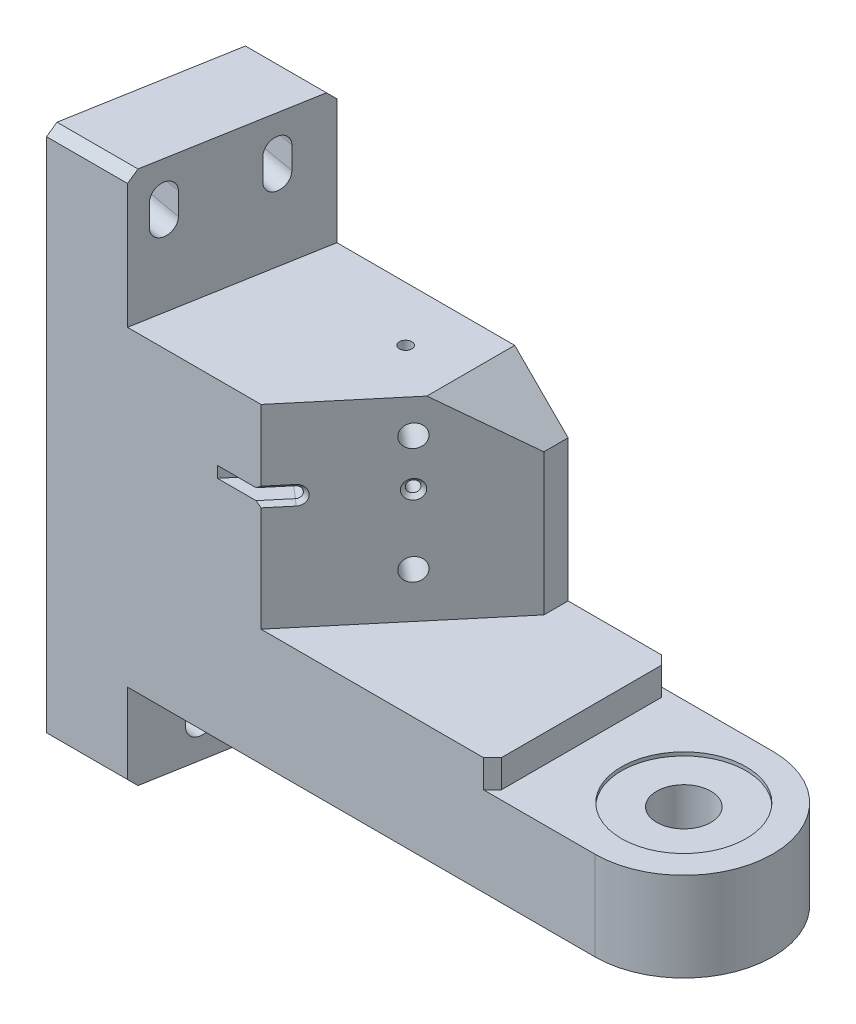
from build123d import *

# Parameters (mm, degrees)
SKETCH1_W                              = 181.864
SKETCH1_H                              = 50.8
EXTRUDE1_DEPTH                         = 152.4
EXTRUDE2_DEPTH                         = 153.4
EXTRUDE3_DEPTH                         = 38.1
EXTRUDE4_DEPTH                         = 55.5498
SKETCH5_W                              = 54.61
SKETCH5_H                              = 50.8
EXTRUDE5_DEPTH                         = 7.9502
EXTRUDE6_DEPTH                         = 25.4
EXTRUDE7_DEPTH                         = 32.584173829
LPATTERN1_COUNT                        = 2
LPATTERN1_PITCH                        = 127
LPATTERN1_COUNT_DIR2                   = 2
LPATTERN1_PITCH_DIR2                   = 27.94
F_1_4_20_TAPPED_HOLE1_D                = 5.1054
F_1_4_20_TAPPED_HOLE1_DEPTH            = 16.51
F_1_4_20_TAPPED_HOLE1_CBORE_D          = 6.35
F_1_4_20_TAPPED_HOLE1_CBORE_DEPTH      = 12.7
F_1_4_20_TAPPED_HOLE1_TIP              = 1.533816902
EXTRUDE9_DEPTH                         = 128
CHAMFER1_SIZE                          = 2.54
CHAMFER2_SIZE                          = 15.24
EXTRUDE10_DEPTH                        = 32.584173829
SCREW_THRU_HOLE_AND_CBORE_D            = 15.4686
SCREW_THRU_HOLE_AND_CBORE_CBORE_D      = 35.56
SCREW_THRU_HOLE_AND_CBORE_CBORE_DEPTH  = 1.016
F_1_8_0_125_DIAMETER_HOLE1_D           = 3.19024
F_1_8_0_125_DIAMETER_HOLE1_DEPTH       = 9.525
F_1_8_0_125_DIAMETER_HOLE1_CSINK_D     = 5.334
F_1_8_0_125_DIAMETER_HOLE1_CSINK_ANGLE = 90
F_1_8_0_125_DIAMETER_HOLE1_TIP         = 0.958444791
CUT_EXTRUDE1_DEPTH                     = 9.525
CHAMFER3_SIZE                          = 1.0795
F_9_64_0_14063_DIAMETER_HOLE1_D        = 3.572002
F_9_64_0_14063_DIAMETER_HOLE1_DEPTH    = 43.18
F_1_16_0_0625_DIAMETER_HOLE1_D         = 1.5875
F_1_16_0_0625_DIAMETER_HOLE1_DEPTH     = 16.51


with BuildPart() as part:
    # Sketch1 → Extrude1 (new body)
    with BuildSketch(Plane(origin=(0, 0, 0), x_dir=(1, 0, 0), z_dir=(0, 1, 0))):
        with Locations((-65.532, 0)):
            Rectangle(SKETCH1_W, SKETCH1_H)
    extrude(amount=EXTRUDE1_DEPTH)

    # Sketch2 → Extrude2 (cut, through all)
    with BuildSketch(Plane(origin=(0, 152.4, 0), x_dir=(1, 0, 0), z_dir=(0, 1, 0))):
        Polygon((-156.464, -25.4), (-156.464, 25.4), (-147.50658938, 25.4), align=None)
    extrude(amount=-EXTRUDE2_DEPTH, mode=Mode.SUBTRACT)

    # Sketch3 → Extrude3 (cut)
    with BuildSketch(Plane(origin=(0, 152.4, 0), x_dir=(1, 0, 0), z_dir=(0, 1, 0))):
        Polygon((25.4, -25.4), (25.4, 25.4), (-124.39258938, 25.4), (-133.35, -25.4), align=None)
    extrude(amount=-EXTRUDE3_DEPTH, mode=Mode.SUBTRACT)

    # Sketch4 → Extrude4 (cut)
    with BuildSketch(Plane(origin=(0, 114.3, 0), x_dir=(1, 0, 0), z_dir=(0, 1, 0))):
        Polygon((25.4, -25.4), (-95.25, -25.4), (-58.42, 18.492284815), (-58.42, 25.4), (25.4, 25.4), align=None)
    extrude(amount=-EXTRUDE4_DEPTH, mode=Mode.SUBTRACT)

    # Sketch5 → Extrude5 (cut)
    with BuildSketch(Plane(origin=(0, 58.7502, 0), x_dir=(1, 0, 0), z_dir=(0, 1, 0))):
        with Locations((-1.905, 0)):
            Rectangle(SKETCH5_W, SKETCH5_H)
    extrude(amount=-EXTRUDE5_DEPTH, mode=Mode.SUBTRACT)

    # Sketch6 → Extrude6 (cut)
    with BuildSketch(Plane.XZ):
        Polygon((25.4, 25.4), (25.4, -25.4), (-124.39258938, -25.4), (-133.35, 25.4), align=None)
    extrude(amount=-EXTRUDE6_DEPTH, mode=Mode.SUBTRACT)

    # Sketch7 → Extrude7 (cut, through all)
    with BuildSketch(Plane(origin=(-124.985349671, 0, -22.03828934), x_dir=(0.173648178, 0, -0.984807753), z_dir=(0.984807753, 0, 0.173648178))):
        with BuildLine():
            Line((-35.635705397, 142.9766), (-35.635705397, 136.6266))
            ThreePointArc((-35.635705397, 136.6266), (-39.204405397, 133.0579), (-42.773105397, 136.6266))
            Line((-42.773105397, 136.6266), (-42.773105397, 142.9766))
            ThreePointArc((-42.773105397, 142.9766), (-39.204405397, 146.5453), (-35.635705397, 142.9766))
        make_face()
    extrude7 = extrude(amount=-EXTRUDE7_DEPTH, mode=Mode.SUBTRACT)

    # LPattern1: Extrude7 2 × 2, 1 skipped
    with Locations(*[Vector(0, -1, 0) * (i * LPATTERN1_PITCH) + Vector(0.173648178, 0, -0.984807753) * (j * LPATTERN1_PITCH_DIR2) for i in range(LPATTERN1_COUNT) for j in range(LPATTERN1_COUNT_DIR2) if (i, j) not in ((0, 0), (1, 0))]):
        add(extrude7, mode=Mode.SUBTRACT)

    # 1/4-20 Tapped Hole1
    with Locations(Plane(origin=(-43.387935998, 0, -36.406801094), x_dir=(0.64278761, 0, -0.766044443), z_dir=(0.766044443, 0, 0.64278761))):
        with Locations((-49.822048678, 104.648), (-49.822048678, 71.628)):
            CounterBoreHole(F_1_4_20_TAPPED_HOLE1_D / 2, F_1_4_20_TAPPED_HOLE1_CBORE_D / 2, F_1_4_20_TAPPED_HOLE1_CBORE_DEPTH, depth=F_1_4_20_TAPPED_HOLE1_DEPTH)
            with Locations((0, 0, -(F_1_4_20_TAPPED_HOLE1_DEPTH + F_1_4_20_TAPPED_HOLE1_TIP / 2))):  # 118° drill point
                Cone(0, F_1_4_20_TAPPED_HOLE1_D / 2, F_1_4_20_TAPPED_HOLE1_TIP, mode=Mode.SUBTRACT)

    # Sketch19 → Extrude9 (cut, through all)
    with BuildSketch(Plane.XZ.offset(-25.4)):
        with BuildLine():
            Line((27.94, 25.4), (0, 25.4))
            ThreePointArc((0, 25.4), (25.4, 0), (0, -25.4))
            Line((0, -25.4), (27.94, -25.4))
            Line((27.94, -25.4), (27.94, 25.4))
        make_face()
    extrude(amount=-EXTRUDE9_DEPTH, mode=Mode.SUBTRACT)

    # Chamfer1
    chamfer1_edges = [part.edges().sort_by_distance(p)[0] for p in [
        (-135.94958938, 152.4, -25.4),
        (-144.907, 0, 25.4),
        (-29.21, 54.7751, 25.4),
        (-29.21, 54.7751, -25.4),
        (-135.94958938, 0, -25.4),
        (-144.907, 152.4, 25.4),
    ]]
    chamfer(chamfer1_edges, length=CHAMFER1_SIZE)

    # Chamfer2
    chamfer2_edges = [part.edges().sort_by_distance(p)[0] for p in [
        (-58.42, 114.3, -21.946142408),
    ]]
    chamfer(chamfer2_edges, length=CHAMFER2_SIZE)

    # Sketch20 → Extrude10 (cut, through all)
    with BuildSketch(Plane(origin=(-124.985349671, 0, -22.03828934), x_dir=(0.173648178, 0, -0.984807753), z_dir=(0.984807753, 0, 0.173648178))):
        with BuildLine():
            Line((-26.745705397, 15.9766), (-26.745705397, 9.6266))
            ThreePointArc((-26.745705397, 9.6266), (-30.314405397, 6.0579), (-33.883105397, 9.6266))
            Line((-33.883105397, 9.6266), (-33.883105397, 15.9766))
            ThreePointArc((-33.883105397, 15.9766), (-30.314405397, 19.5453), (-26.745705397, 15.9766))
        make_face()
    extrude(amount=-EXTRUDE10_DEPTH, mode=Mode.SUBTRACT)

    # SCREW THRU HOLE AND CBORE (through all)
    with Locations(Plane(origin=(0, 50.8, 0), x_dir=(-1, 0, 0), z_dir=(0, 1, 0))):
        with Locations((0, 0)):
            CounterBoreHole(SCREW_THRU_HOLE_AND_CBORE_D / 2, SCREW_THRU_HOLE_AND_CBORE_CBORE_D / 2, SCREW_THRU_HOLE_AND_CBORE_CBORE_DEPTH)

    # 1/8 (0.125) Diameter Hole1
    with Locations(Plane(origin=(-43.387935998, 0, -36.406801094), x_dir=(0.64278761, 0, -0.766044443), z_dir=(0.766044443, 0, 0.64278761))):
        with Locations((-49.784, 91.412613047)):
            CounterSinkHole(F_1_8_0_125_DIAMETER_HOLE1_D / 2, F_1_8_0_125_DIAMETER_HOLE1_CSINK_D / 2, depth=F_1_8_0_125_DIAMETER_HOLE1_DEPTH, counter_sink_angle=F_1_8_0_125_DIAMETER_HOLE1_CSINK_ANGLE)
            with Locations((0, 0, -(F_1_8_0_125_DIAMETER_HOLE1_DEPTH + F_1_8_0_125_DIAMETER_HOLE1_TIP / 2))):  # 118° drill point
                Cone(0, F_1_8_0_125_DIAMETER_HOLE1_D / 2, F_1_8_0_125_DIAMETER_HOLE1_TIP, mode=Mode.SUBTRACT)

    # Sketch26 → Cut-Extrude1 (cut)
    with BuildSketch(Plane(origin=(-43.387935998, 0, -36.406801094), x_dir=(0.64278761, 0, -0.766044443), z_dir=(0.766044443, 0, 0.64278761))):
        with BuildLine():
            Line((-73.6092, 89.817493047), (-92.6592, 89.817493047))
            ThreePointArc((-92.6592, 89.817493047), (-94.25432, 91.412613047), (-92.6592, 93.007733047))
            Line((-92.6592, 93.007733047), (-73.6092, 93.007733047))
            ThreePointArc((-73.6092, 93.007733047), (-72.01408, 91.412613047), (-73.6092, 89.817493047))
        make_face()
    extrude(amount=-CUT_EXTRUDE1_DEPTH, mode=Mode.SUBTRACT)

    # Chamfer3
    chamfer3_edges = [part.edges().sort_by_distance(p)[0] for p in [
        (-92.976508859, 89.817493047, 22.690558764),
        (-92.976508859, 93.007733047, 22.690558764),
        (-89.677694345, 91.412613047, 18.759184717),
    ]]
    chamfer(chamfer3_edges, length=CHAMFER3_SIZE)

    # 9/64 (0.14063) Diameter Hole1
    with Locations(Plane(origin=(0, 114.3, 0), x_dir=(-1, 0, 0), z_dir=(0, 1, 0))):
        with Locations((89.235297248, -9.839239495)):
            Hole(F_9_64_0_14063_DIAMETER_HOLE1_D / 2, depth=F_9_64_0_14063_DIAMETER_HOLE1_DEPTH)

    # 1/16 (0.0625) Diameter Hole1
    with Locations(Plane(origin=(-43.387935998, 0, -36.406801094), x_dir=(0.64278761, 0, -0.766044443), z_dir=(0.766044443, 0, 0.64278761))):
        with Locations((-49.784, 91.412613047)):
            Hole(F_1_16_0_0625_DIAMETER_HOLE1_D / 2, depth=F_1_16_0_0625_DIAMETER_HOLE1_DEPTH)


solid = part.part
